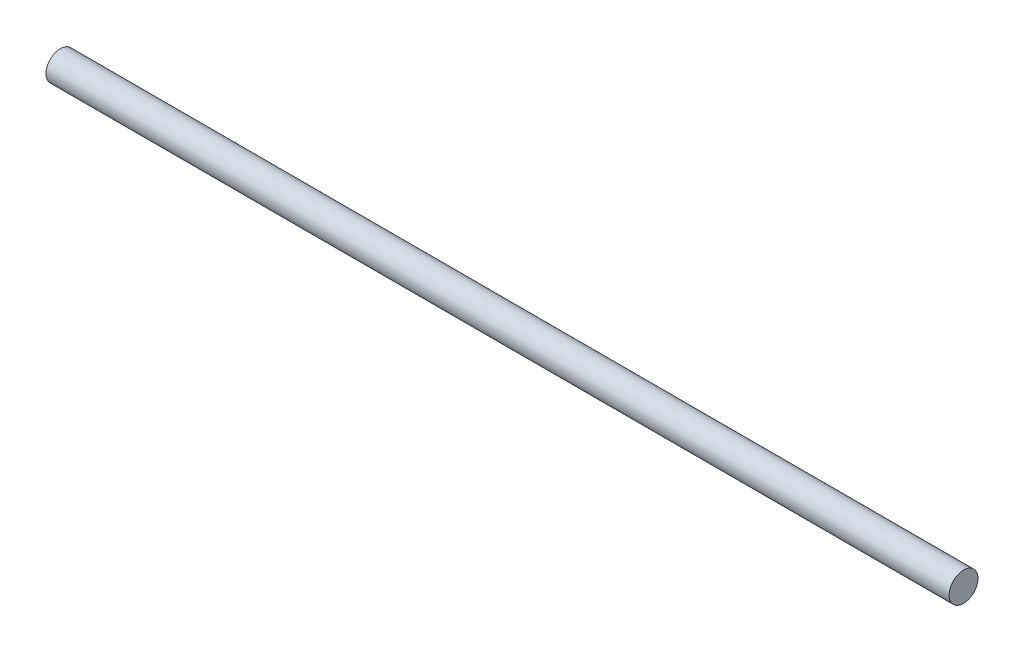
from build123d import *

# Parameters (mm, degrees)
SKETCH2_R           = 4
BOSS_EXTRUDE1_DEPTH = 250


with BuildPart() as part:
    # Sketch2 → Boss-Extrude1 (new body)
    with BuildSketch(Plane(origin=(0, 0, 0), x_dir=(0, 0, -1), z_dir=(1, 0, 0))):
        Circle(SKETCH2_R)
    extrude(amount=BOSS_EXTRUDE1_DEPTH)


solid = part.part
